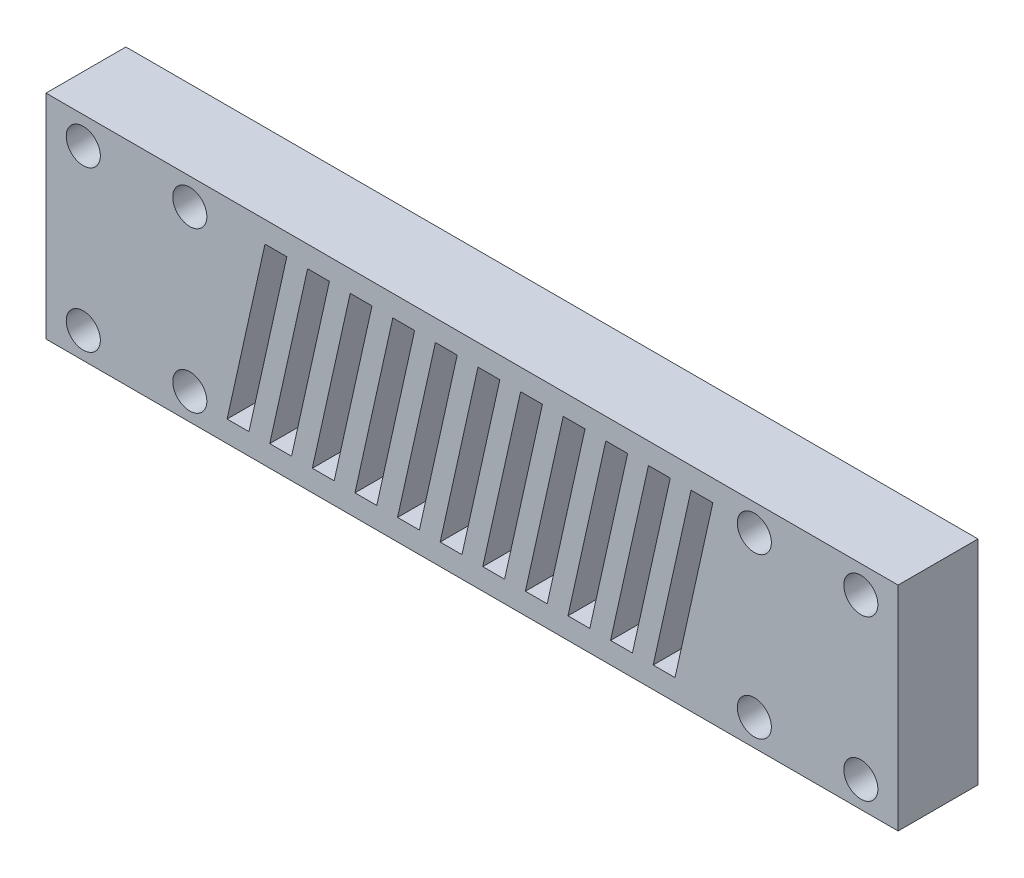
from build123d import *

# Parameters (mm, degrees)
SKETCH1_W           = 80
SKETCH1_H           = 20
SKETCH1_R           = 1.6
BOSS_EXTRUDE4_DEPTH = 7.5
CUT_EXTRUDE1_DEPTH  = 7.5


with BuildPart() as part:
    # Sketch1 → Boss-Extrude4 (new body)
    with BuildSketch(Plane.XY):
        with Locations((0, -0.350941688)):
            Rectangle(SKETCH1_W, SKETCH1_H)
        with Locations((36.5, 7.096795016)):
            Circle(SKETCH1_R, mode=Mode.SUBTRACT)
        with Locations((26.5, 7.149058312)):
            Circle(SKETCH1_R, mode=Mode.SUBTRACT)
        with Locations((36.5, -7.903204984)):
            Circle(SKETCH1_R, mode=Mode.SUBTRACT)
        with Locations((26.5, -7.850941688)):
            Circle(SKETCH1_R, mode=Mode.SUBTRACT)
        with Locations(Location((-26.5, -7.850941688, 0), (0, 0, 180))):  # turned: the seam where the file's is
            Circle(SKETCH1_R, mode=Mode.SUBTRACT)
        with Locations(Location((-36.5, -7.903204984, 0), (0, 0, 180))):  # turned: the seam where the file's is
            Circle(SKETCH1_R, mode=Mode.SUBTRACT)
        with Locations(Location((-26.5, 7.149058312, 0), (0, 0, 180))):  # turned: the seam where the file's is
            Circle(SKETCH1_R, mode=Mode.SUBTRACT)
        with Locations(Location((-36.5, 7.096795016, 0), (0, 0, 180))):  # turned: the seam where the file's is
            Circle(SKETCH1_R, mode=Mode.SUBTRACT)
    extrude(amount=BOSS_EXTRUDE4_DEPTH)

    # Sketch6 → Cut-Extrude1 (cut)
    with BuildSketch(Plane.XY.offset(7.5)):
        Polygon((-19.441029478, 7.649058312), (-22.994766049, -8.350941688), (-20.946027704, -8.350941688), (-17.392291133, 7.649058312), align=None)
        Polygon((-13.392291133, 7.649058312), (-15.441029478, 7.649058312), (-18.994766049, -8.350941688), (-16.946027704, -8.350941688), align=None)
        Polygon((-9.392291133, 7.649058312), (-11.441029478, 7.649058312), (-14.994766049, -8.350941688), (-12.946027704, -8.350941688), align=None)
        Polygon((-5.392291133, 7.649058312), (-7.441029478, 7.649058312), (-10.994766049, -8.350941688), (-8.946027704, -8.350941688), align=None)
        Polygon((-1.392291133, 7.649058312), (-3.441029478, 7.649058312), (-6.994766049, -8.350941688), (-4.946027704, -8.350941688), align=None)
        Polygon((2.607708867, 7.649058312), (0.558970522, 7.649058312), (-2.994766049, -8.350941688), (-0.946027704, -8.350941688), align=None)
        Polygon((6.607708867, 7.649058312), (4.558970522, 7.649058312), (1.005233951, -8.350941688), (3.053972296, -8.350941688), align=None)
        Polygon((10.607708867, 7.649058312), (8.558970522, 7.649058312), (5.005233951, -8.350941688), (7.053972296, -8.350941688), align=None)
        Polygon((14.607708867, 7.649058312), (12.558970522, 7.649058312), (9.005233951, -8.350941688), (11.053972296, -8.350941688), align=None)
        Polygon((18.607708867, 7.649058312), (16.558970522, 7.649058312), (13.005233951, -8.350941688), (15.053972296, -8.350941688), align=None)
        Polygon((22.607708867, 7.649058312), (20.558970522, 7.649058312), (17.005233951, -8.350941688), (19.053972296, -8.350941688), align=None)
    extrude(amount=-CUT_EXTRUDE1_DEPTH, mode=Mode.SUBTRACT)


solid = part.part
